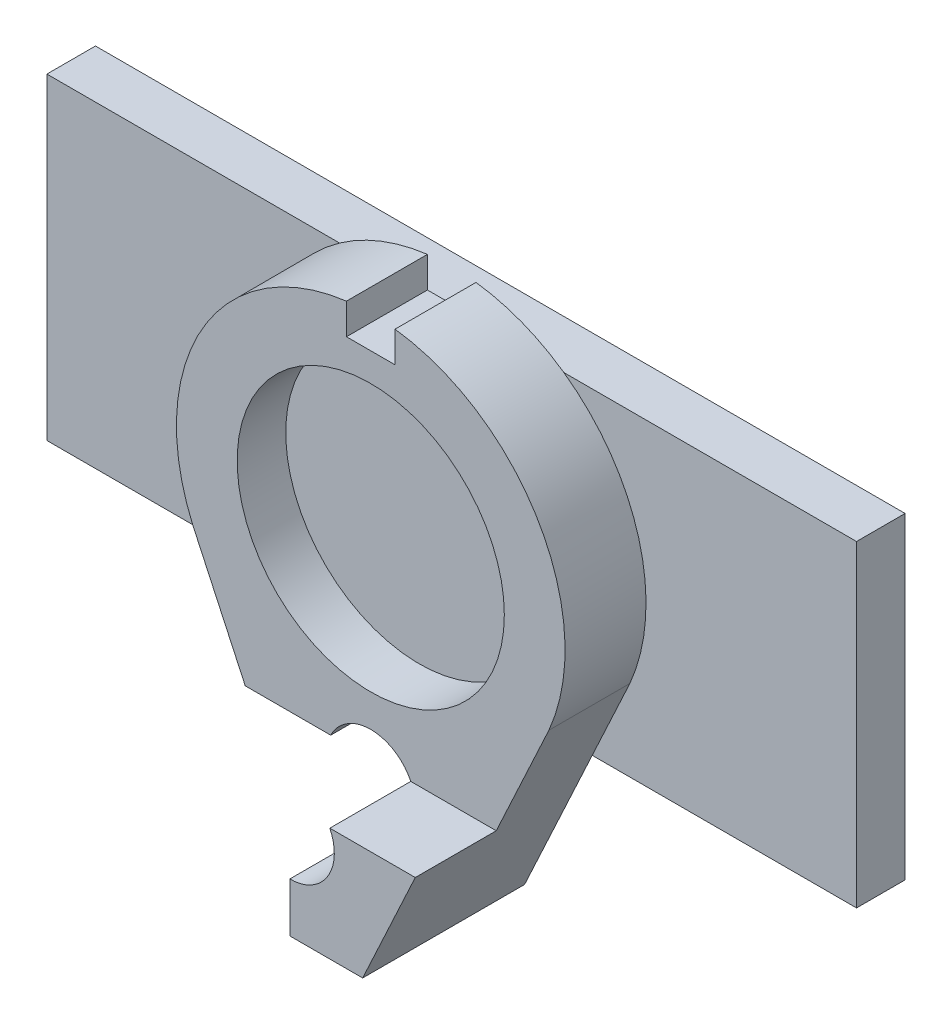
from build123d import *

# Parameters (mm, degrees)
BOSS_EXTRU_1_DEPTH           = 5
ESQUISSE2_R                  = 8.25
ENL_V_MAT_EXTRU_1_DEPTH      = 3
ESQUISSE4_W                  = 3
ESQUISSE4_H                  = 5
ENL_V_MAT_EXTRU_2_DEPTH      = 2
BOSS_EXTRU_2_DEPTH           = 5
ENL_V_MAT_EXTRU_4_DEPTH      = 5
ESQUISSE8_W                  = 50
ESQUISSE8_H                  = 19.6
BOSS_EXTRU_3_DEPTH           = 3
ESQUISSE10_R                 = 2.75
ENL_V_MAT_EXTRU_5_DEPTH      = 6
ENL_V_MAT_EXTRU_5_DEPTH_BACK = 9


with BuildPart() as part:
    # Esquisse1 → Boss.-Extru.1 (new body)
    with BuildSketch(Plane.XY):
        with BuildLine():
            Line((-11, -4.795831523), (-4.5, -18.795831523))
            Line((-4.5, -18.795831523), (4.5, -18.795831523))
            Line((4.5, -18.795831523), (11, -4.795831523))
            ThreePointArc((11, -4.795831523), (0, 12), (-11, -4.795831523))
        make_face()
    extrude(amount=BOSS_EXTRU_1_DEPTH)

    # Esquisse2 → Enlèv. mat.-Extru.1 (cut)
    with BuildSketch(Plane.XY.offset(5)):
        Circle(ESQUISSE2_R)
    extrude(amount=-ENL_V_MAT_EXTRU_1_DEPTH, mode=Mode.SUBTRACT)

    # Esquisse4 → Enlèv. mat.-Extru.2 (cut)
    with BuildSketch(Plane(origin=(0, 12, 0), x_dir=(1, 0, 0), z_dir=(0, 1, 0))):
        with Locations((0, -2.5)):
            Rectangle(ESQUISSE4_W, ESQUISSE4_H)
    extrude(amount=-ENL_V_MAT_EXTRU_2_DEPTH, mode=Mode.SUBTRACT)

    # Esquisse6 → Boss.-Extru.2 (add)
    with BuildSketch(Plane.XY.offset(5)):
        Polygon((0, -18.795831523), (4.5, -18.795831523), (7.75, -11.795831523), (0, -11.795831523), align=None)
    extrude(amount=BOSS_EXTRU_2_DEPTH)

    # Esquisse7 → Enlèv. mat.-Extru.4 (cut)
    with BuildSketch(Plane.XY.offset(5)):
        Polygon((0, -18.795831523), (0, -11.795831523), (-7.75, -11.795831523), (-4.5, -18.795831523), align=None)
    extrude(amount=-ENL_V_MAT_EXTRU_4_DEPTH, mode=Mode.SUBTRACT)

    # Esquisse8 → Boss.-Extru.3 (add)
    with BuildSketch(Plane(origin=(0, 0, 0), x_dir=(-1, 0, 0), z_dir=(0, 0, -1))):
        Rectangle(ESQUISSE8_W, ESQUISSE8_H)
    extrude(amount=BOSS_EXTRU_3_DEPTH)

    # Esquisse10 → Enlèv. mat.-Extru.5 (cut, two sides)
    with BuildSketch(Plane.XY.offset(5)) as enl_v_mat_extru_5_sk:
        with Locations((0, -13)):
            Circle(ESQUISSE10_R)
    extrude(amount=ENL_V_MAT_EXTRU_5_DEPTH, mode=Mode.SUBTRACT)
    extrude(enl_v_mat_extru_5_sk.sketch, amount=-ENL_V_MAT_EXTRU_5_DEPTH_BACK, mode=Mode.SUBTRACT)


solid = part.part
